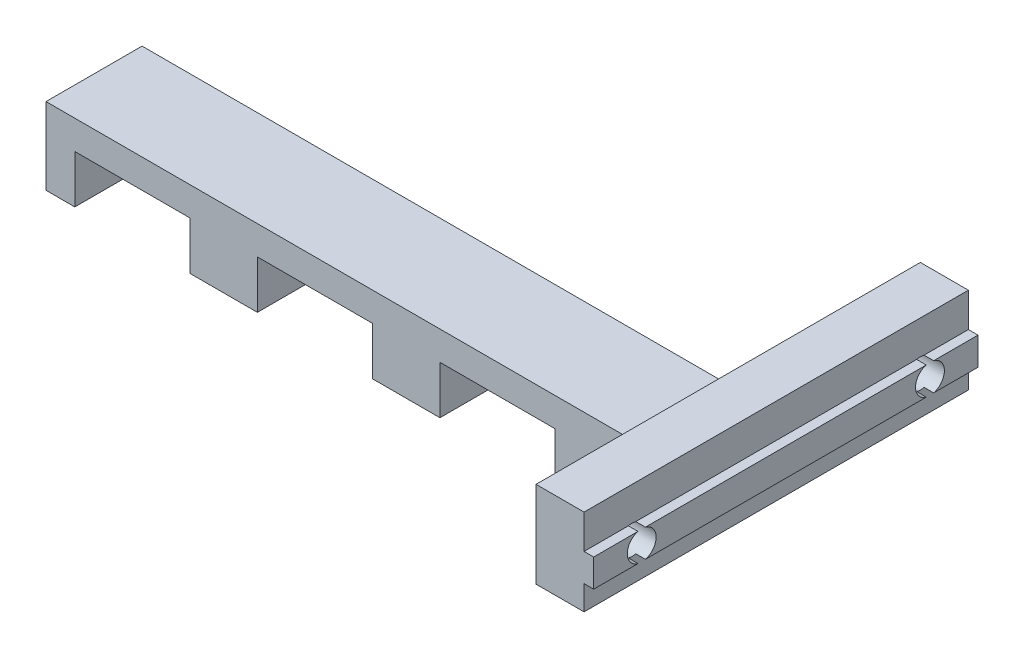
from build123d import *

# Parameters (mm, degrees)
MAIN_DEPTH             = 5
MAKERBEAMFIX_DEPTH     = 20
SKETCH2_R              = 1.5
MAKERBEAMFIXHOLE_DEPTH = 30
FILLET1_R              = 5


with BuildPart() as part:
    # Esquisse1 → Main (new body, symmetric)
    with BuildSketch(Plane.XY):
        Polygon((3, 0), (3, 5), (15, 5), (15, 0), (22, 0), (22, 5), (34, 5), (34, 0), (41, 0), (41, 5), (53, 5), (53, 0), (60, 0), (60, 5), (71, 5), (71, 8), (0, 8), (0, 0), align=None)
    extrude(amount=MAIN_DEPTH, both=True)

    # Sketch1 → MakerBeamFix (add, symmetric)
    with BuildSketch(Plane.XY):
        Polygon((66, 14), (71, 14), (71, 10.45), (72, 10.45), (72, 7.55), (71, 7.55), (71, 5), (66, 5), align=None)
    extrude(amount=MAKERBEAMFIX_DEPTH, both=True)

    # Sketch2 → MakerBeamFixHole (cut)
    with BuildSketch(Plane(origin=(72, 0, 0), x_dir=(0, 0, -1), z_dir=(1, 0, 0))):
        with Locations((-15, 9)):
            Circle(SKETCH2_R)
        with Locations((15, 9)):
            Circle(SKETCH2_R)
    extrude(amount=-MAKERBEAMFIXHOLE_DEPTH, mode=Mode.SUBTRACT)

    # Fillet1
    fillet1_edges = [part.edges().sort_by_distance(p)[0] for p in [
        (66, 6.5, -5),
        (66, 6.5, 5),
        (66, 8, 0),
    ]]
    fillet(fillet1_edges, radius=FILLET1_R)


solid = part.part
